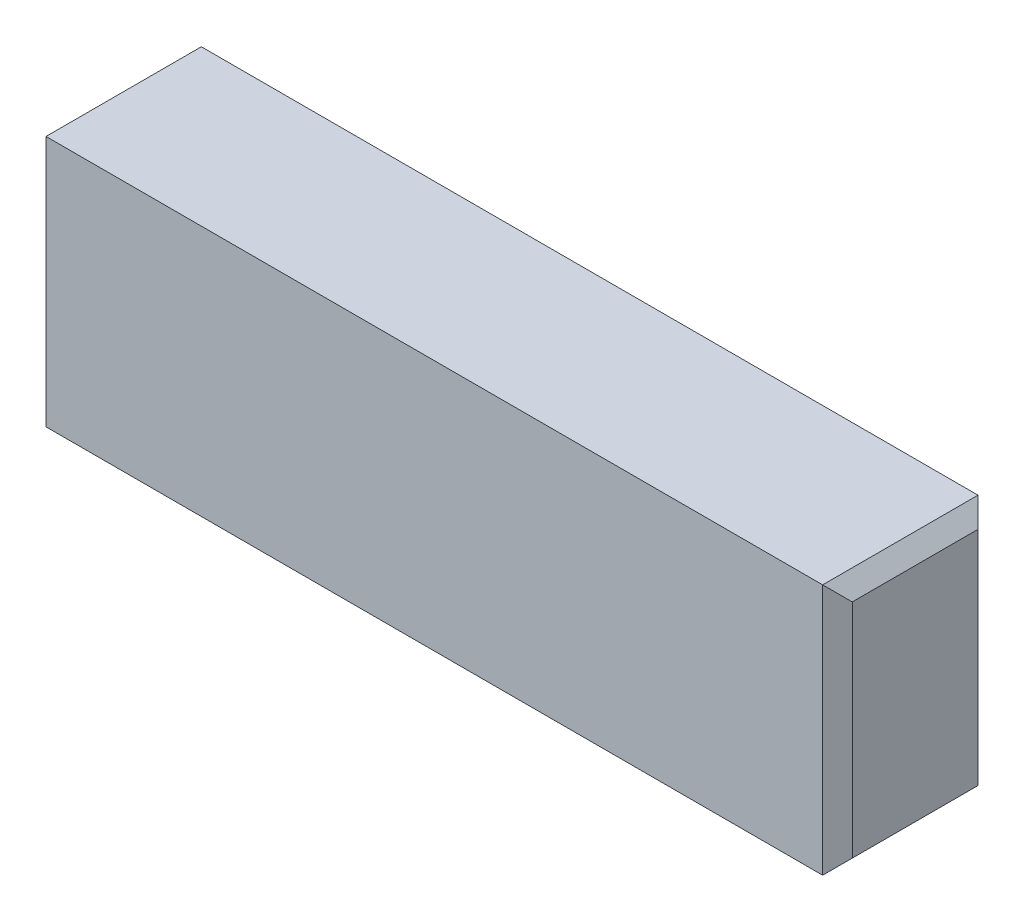
from build123d import *

# Parameters (mm, degrees)
SKETCH1_W           = 109
SKETCH1_H           = 34
BOSS_EXTRUDE1_DEPTH = 21
CHAMFER1_SIZE       = 2


with BuildPart() as part:
    # Sketch1 → Boss-Extrude1 (new body)
    with BuildSketch(Plane.XY):
        Rectangle(SKETCH1_W, SKETCH1_H)
    extrude(amount=BOSS_EXTRUDE1_DEPTH)

    # Chamfer1
    chamfer1_edges = [part.edges().sort_by_distance(p)[0] for p in [
        (-54.5, 0, 21),
        (54.5, 0, 21),
        (-54.5, 0, 0),
        (54.5, 0, 0),
        (54.5, -17, 10.5),
        (-54.5, -17, 10.5),
        (-54.5, 17, 10.5),
        (54.5, 17, 10.5),
    ]]
    chamfer(chamfer1_edges, length=CHAMFER1_SIZE)


solid = part.part
